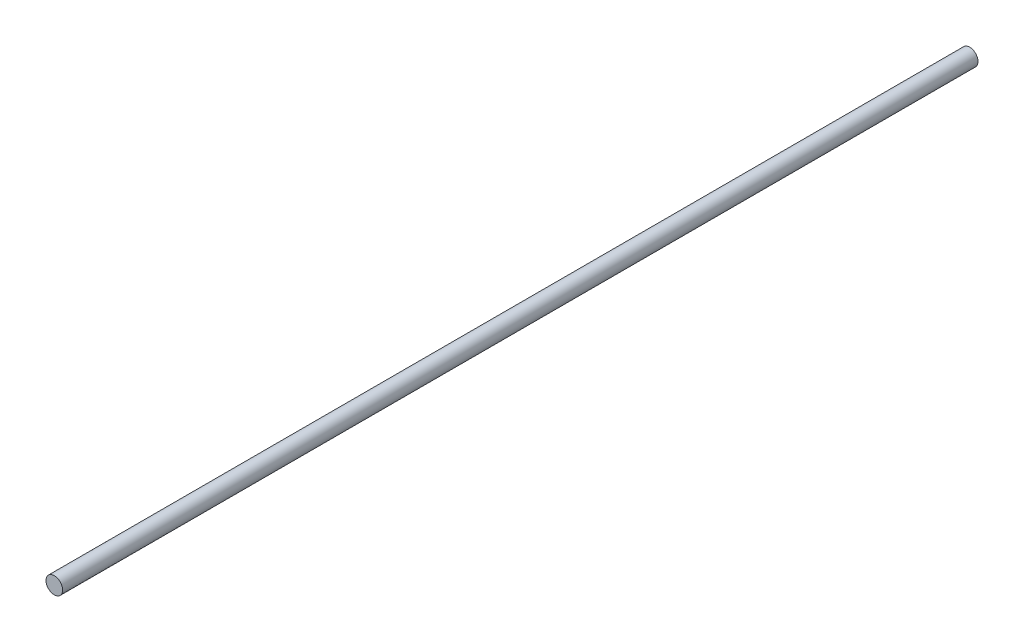
from build123d import *

# Parameters (mm, degrees)
SKETCH1_R           = 3.175
BOSS_EXTRUDE1_DEPTH = 349.425999902


with BuildPart() as part:
    # Sketch1 → Boss-Extrude1 (new body)
    with BuildSketch(Plane.XY):
        Circle(SKETCH1_R)
    extrude(amount=BOSS_EXTRUDE1_DEPTH)


solid = part.part
